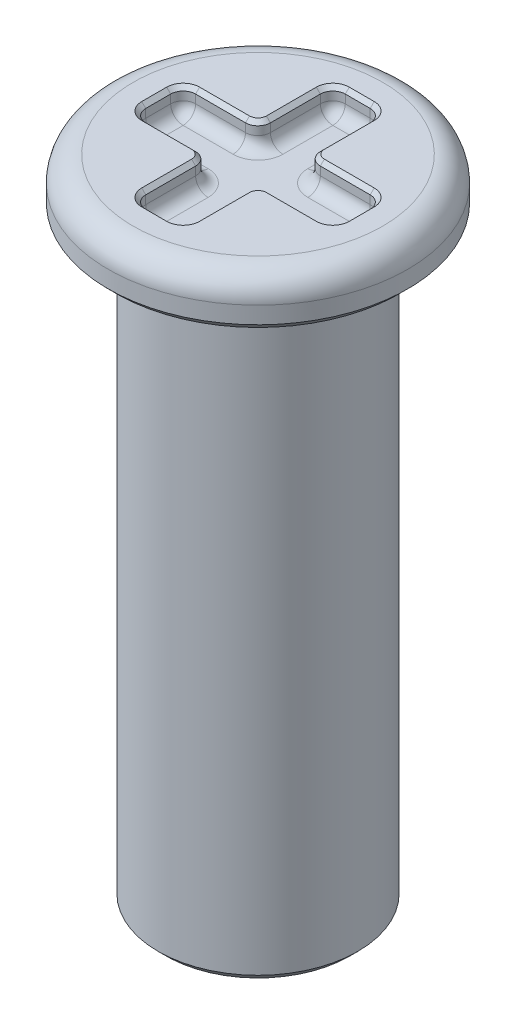
from build123d import *

# Parameters (mm, degrees)
CUT_EXTRUDE1_DEPTH = 0.79375
FILLET1_R          = 0.79375
FILLET2_R          = 0.396875
CHAMFER1_SIZE      = 0.254
CHAMFER2_SIZE      = 0.127


with BuildPart() as part:
    # Sketch1 → Revolve1 (revolve)
    with BuildSketch(Plane.XY):
        Polygon((2.38125, 0), (3.175, 0), (3.175, 19.05), (4.7625, 19.05), (4.7625, 20.6375), (0, 20.6375), (0, 19.05), (2.38125, 19.05), align=None)
    revolve(axis=Axis((0, 3.655427632, 0), (0, -1, 0)))

    # Sketch2 → Cut-Extrude1 (cut)
    with BuildSketch(Plane(origin=(0, 20.6375, 0), x_dir=(1, 0, 0), z_dir=(0, 1, 0))):
        Polygon((-3.175, 0.79375), (-3.175, -0.79375), (-0.79375, -0.79375), (-0.79375, -3.175), (0.79375, -3.175), (0.79375, -0.79375), (3.175, -0.79375), (3.175, 0.79375), (0.79375, 0.79375), (0.79375, 3.175), (-0.79375, 3.175), (-0.79375, 0.79375), align=None)
    extrude(amount=-CUT_EXTRUDE1_DEPTH, mode=Mode.SUBTRACT)

    # Fillet1
    fillet1_edges = [part.edges().sort_by_distance(p)[0] for p in [
        (-4.7625, 20.6375, 0),
        (-3.175, 19.05, 0),
    ]]
    fillet(fillet1_edges, radius=FILLET1_R)

    # Fillet2
    fillet2_edges = [part.edges().sort_by_distance(p)[0] for p in [
        (0, 19.84375, -3.175),
        (-0.79375, 20.240625, -3.175),
        (0.79375, 19.84375, -1.984375),
        (0.79375, 20.240625, -3.175),
        (1.984375, 19.84375, -0.79375),
        (0.79375, 20.240625, -0.79375),
        (3.175, 19.84375, 0),
        (3.175, 20.240625, -0.79375),
        (1.984375, 19.84375, 0.79375),
        (3.175, 20.240625, 0.79375),
        (0.79375, 19.84375, 1.984375),
        (0.79375, 20.240625, 0.79375),
        (0, 19.84375, 3.175),
        (0.79375, 20.240625, 3.175),
        (-0.79375, 19.84375, 1.984375),
        (-0.79375, 20.240625, 3.175),
        (-1.984375, 19.84375, 0.79375),
        (-0.79375, 20.240625, 0.79375),
        (-3.175, 19.84375, 0),
        (-3.175, 20.240625, 0.79375),
        (-1.984375, 19.84375, -0.79375),
        (-3.175, 20.240625, -0.79375),
        (-0.79375, 19.84375, -1.984375),
        (-0.79375, 20.240625, -0.79375),
        (-2.38125, 19.05, 0),
    ]]
    fillet(fillet2_edges, radius=FILLET2_R)

    # Chamfer1
    chamfer1_edges = [part.edges().sort_by_distance(p)[0] for p in [
        (-4.7625, 19.05, 0),
        (-3.175, 0, 0),
        (-2.38125, 0, 0),
    ]]
    chamfer(chamfer1_edges, length=CHAMFER1_SIZE)

    # Chamfer2
    chamfer2_edges = [part.edges().sort_by_distance(p)[0] for p in [
        (0, 20.6375, -3.175),
        (-0.79375, 20.6375, -1.984375),
        (-3.175, 20.6375, 0),
        (-1.984375, 20.6375, 0.79375),
        (-0.79375, 20.6375, 1.984375),
        (0, 20.6375, 3.175),
        (0.79375, 20.6375, 1.984375),
        (1.984375, 20.6375, 0.79375),
        (3.175, 20.6375, 0),
        (1.984375, 20.6375, -0.79375),
        (0.79375, 20.6375, -1.984375),
        (-1.984375, 20.6375, -0.79375),
        (0.909991996, 20.6375, -0.909991996),
        (0.909991996, 20.6375, 0.909991996),
        (-0.909991996, 20.6375, 0.909991996),
        (-0.909991996, 20.6375, -0.909991996),
        (-0.677508004, 20.6375, -3.058758004),
        (-3.058758004, 20.6375, -0.677508004),
        (-3.058758004, 20.6375, 0.677508004),
        (-0.677508004, 20.6375, 3.058758004),
        (0.677508004, 20.6375, 3.058758004),
        (3.058758004, 20.6375, 0.677508004),
        (3.058758004, 20.6375, -0.677508004),
        (0.677508004, 20.6375, -3.058758004),
    ]]
    chamfer(chamfer2_edges, length=CHAMFER2_SIZE)


solid = part.part
